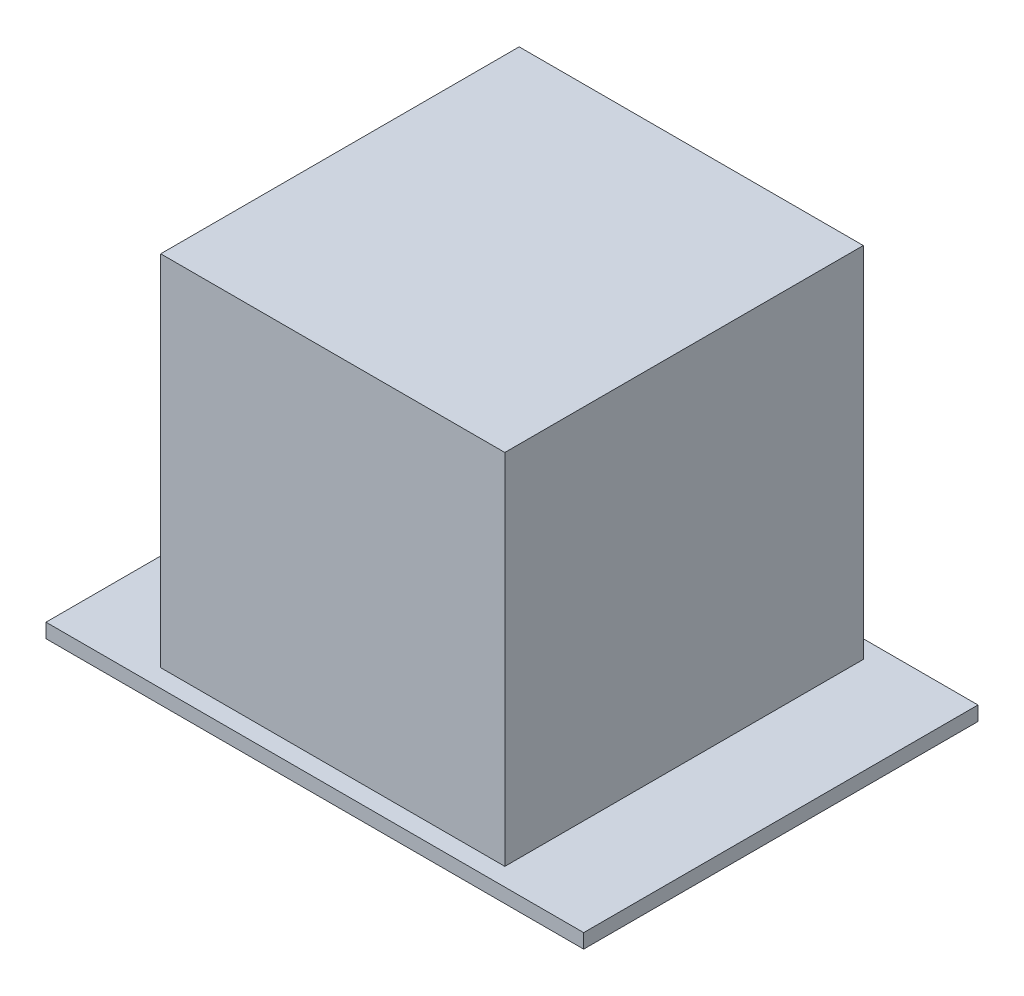
from build123d import *

# Parameters (mm, degrees)
SKETCH1_W           = 150
SKETCH1_H           = 110
BOSS_EXTRUDE1_DEPTH = 4
SKETCH2_W           = 96
SKETCH2_H           = 100
BOSS_EXTRUDE2_DEPTH = 100


with BuildPart() as part:
    # Sketch1 → Boss-Extrude1 (new body)
    with BuildSketch(Plane(origin=(0, 0, 0), x_dir=(1, 0, 0), z_dir=(0, 1, 0))):
        with Locations((75, 55)):
            Rectangle(SKETCH1_W, SKETCH1_H)
    extrude(amount=BOSS_EXTRUDE1_DEPTH)

    # Sketch2 → Boss-Extrude2 (add)
    with BuildSketch(Plane(origin=(0, 4, 0), x_dir=(1, 0, 0), z_dir=(0, 1, 0))):
        with Locations((75, 55)):
            Rectangle(SKETCH2_W, SKETCH2_H)
    extrude(amount=BOSS_EXTRUDE2_DEPTH)


solid = part.part
